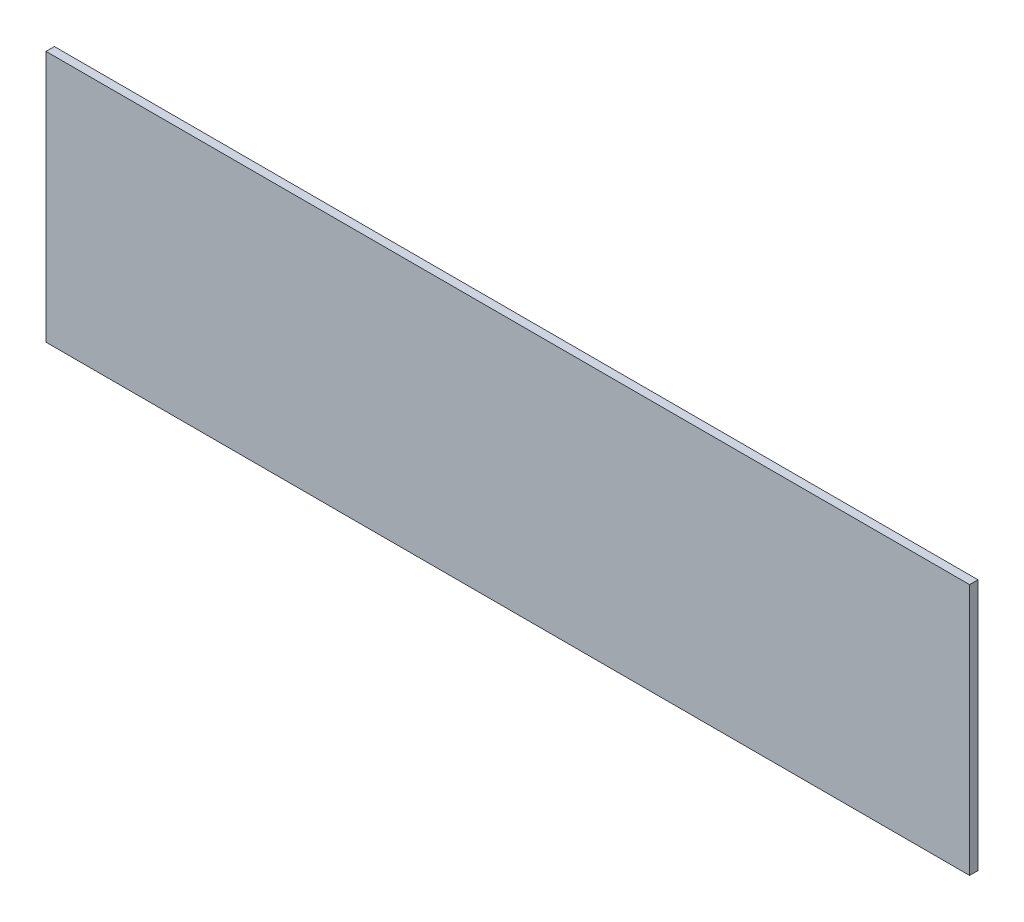
from build123d import *

# Parameters (mm, degrees)
SKETCH1_W           = 550
SKETCH1_H           = 150
BOSS_EXTRUDE1_DEPTH = 5


with BuildPart() as part:
    # Sketch1 → Boss-Extrude1 (new body)
    with BuildSketch(Plane.XY):
        Rectangle(SKETCH1_W, SKETCH1_H)
    extrude(amount=BOSS_EXTRUDE1_DEPTH)


solid = part.part
